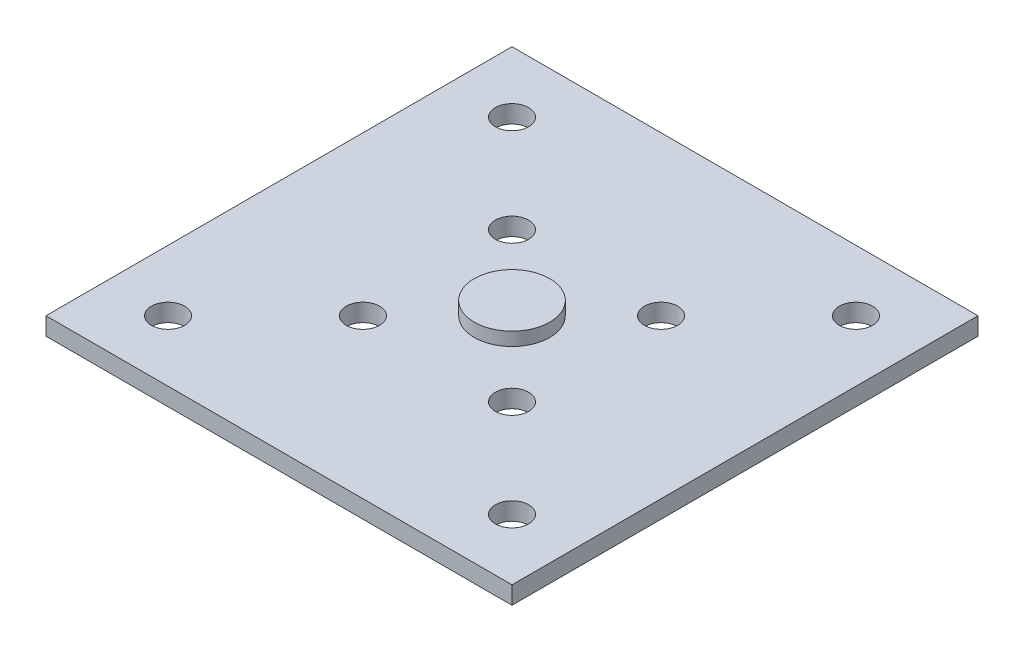
from build123d import *

# Parameters (mm, degrees)
SKETCH_1_W          = 42
SKETCH_1_H          = 42
EXTRUDE_1_DEPTH     = 1.6
SKETCH_2_R          = 1.5
CUT_EXTRUDE_1_DEPTH = 2.6
SKETCH_3_R          = 3.4
EXTRUDE_2_DEPTH     = 1.2
SKETCH_4_R          = 1.5
CUT_EXTRUDE_2_DEPTH = 10


with BuildPart() as part:
    # 草图1 → 凸台-拉伸1 (new body)
    with BuildSketch(Plane(origin=(0, 0, 0), x_dir=(1, 0, 0), z_dir=(0, 1, 0))):
        with Locations((21, 21)):
            Rectangle(SKETCH_1_W, SKETCH_1_H)
    extrude(amount=EXTRUDE_1_DEPTH)

    # 草图2 → 切除-拉伸1 (cut, through all)
    with BuildSketch(Plane(origin=(0, 1.6, 0), x_dir=(1, 0, 0), z_dir=(0, 1, 0))):
        with Locations((5.5, 36.5)):
            Circle(SKETCH_2_R)
        with Locations((36.5, 36.5)):
            Circle(SKETCH_2_R)
        with Locations((5.5, 5.5)):
            Circle(SKETCH_2_R)
        with Locations((36.5, 5.5)):
            Circle(SKETCH_2_R)
    extrude(amount=-CUT_EXTRUDE_1_DEPTH, mode=Mode.SUBTRACT)

    # 草图3 → 凸台-拉伸2 (add)
    with BuildSketch(Plane(origin=(0, 1.6, 0), x_dir=(1, 0, 0), z_dir=(0, 1, 0))):
        with Locations((21, 21)):
            Circle(SKETCH_3_R)
    extrude(amount=EXTRUDE_2_DEPTH)

    # 草图4 → 切除-拉伸2 (cut)
    with BuildSketch(Plane(origin=(0, 1.6, 0), x_dir=(1, 0, 0), z_dir=(0, 1, 0))):
        with Locations((14.282485579, 27.717514421)):
            Circle(SKETCH_4_R)
        with Locations((27.717514421, 27.717514421)):
            Circle(SKETCH_4_R)
        with Locations((14.282485579, 14.282485579)):
            Circle(SKETCH_4_R)
        with Locations((27.717514421, 14.282485579)):
            Circle(SKETCH_4_R)
    extrude(amount=-CUT_EXTRUDE_2_DEPTH, mode=Mode.SUBTRACT)


solid = part.part
